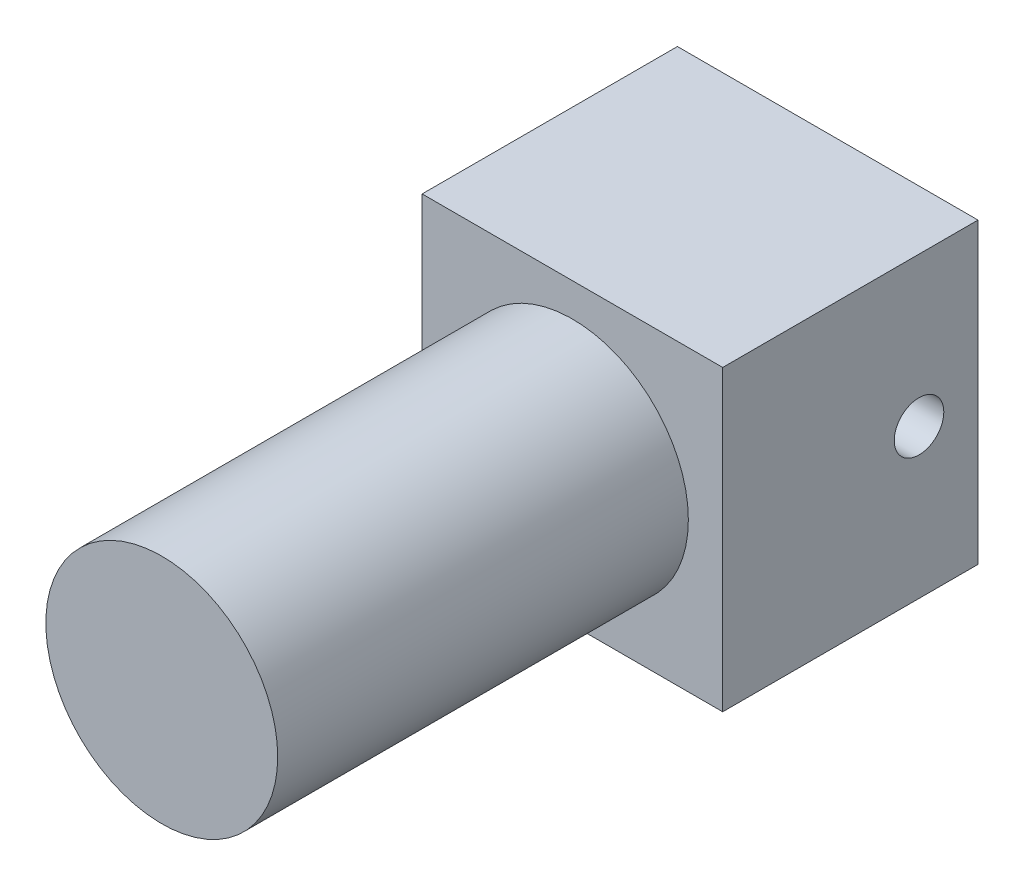
from build123d import *

# Parameters (mm, degrees)
SKETCH1_W           = 38.5
SKETCH1_H           = 38.2
BOSS_EXTRUDE1_DEPTH = 32.7
SKETCH2_R           = 14.85
BOSS_EXTRUDE2_DEPTH = 52.6
SKETCH3_R           = 3.175
CUT_EXTRUDE1_DEPTH  = 7.2136
SKETCH4_R           = 2.06599734
BOSS_EXTRUDE3_DEPTH = 5.08


with BuildPart() as part:
    # Sketch1 → Boss-Extrude1 (new body)
    with BuildSketch(Plane.XY):
        Rectangle(SKETCH1_W, SKETCH1_H)
    extrude(amount=BOSS_EXTRUDE1_DEPTH)

    # Sketch2 → Boss-Extrude2 (add)
    with BuildSketch(Plane.XY.offset(32.7)):
        Circle(SKETCH2_R)
    extrude(amount=BOSS_EXTRUDE2_DEPTH)

    # Sketch3 → Cut-Extrude1 (cut)
    with BuildSketch(Plane(origin=(19.25, 0, 0), x_dir=(0, 0, -1), z_dir=(1, 0, 0))):
        with Locations((-7.554319607, 0)):
            Circle(SKETCH3_R)
    cut_extrude1 = extrude(amount=-CUT_EXTRUDE1_DEPTH, mode=Mode.SUBTRACT)

    # Mirror1: Cut-Extrude1 across plane
    add(cut_extrude1.mirror(Plane(origin=(0, 0, 0), x_dir=(0, 0, 1), z_dir=(1, 0, 0))), mode=Mode.SUBTRACT)

    # Sketch4 → Boss-Extrude3 (add)
    with BuildSketch(Plane(origin=(0, 0, 0), x_dir=(-1, 0, 0), z_dir=(0, 0, -1))):
        with Locations((0, -16.651600327)):
            Circle(SKETCH4_R)
    extrude(amount=BOSS_EXTRUDE3_DEPTH)


solid = part.part
